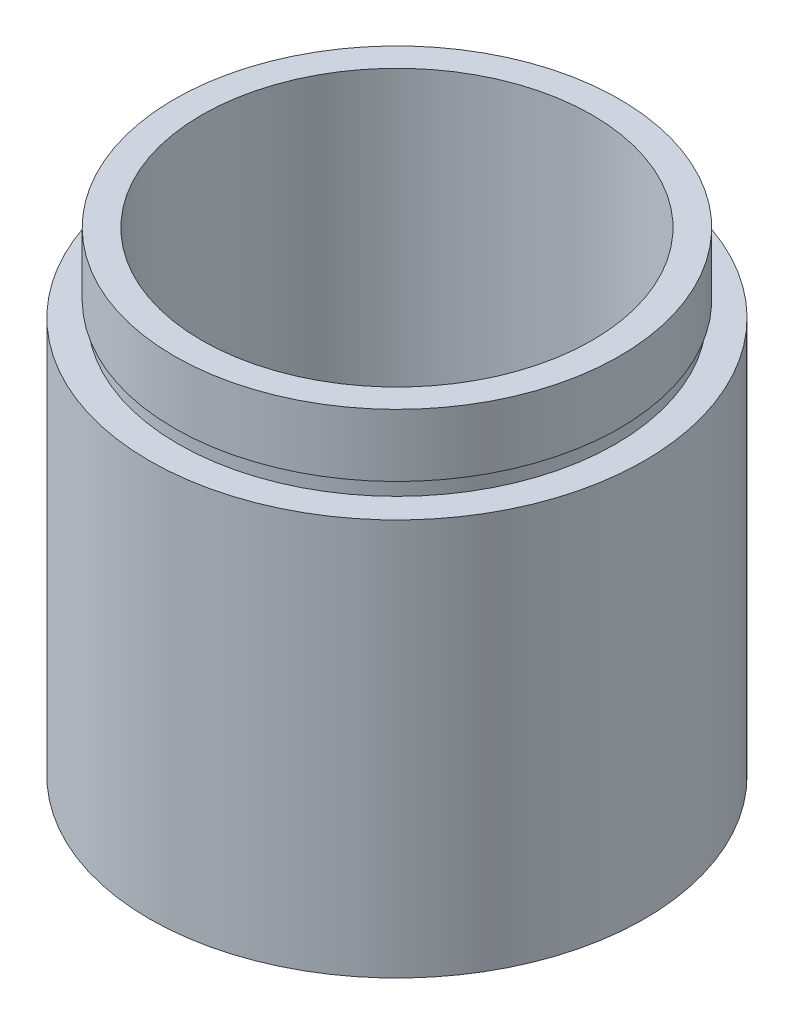
from build123d import *


with BuildPart() as part:
    # 草图1 → 旋转1 (revolve)
    with BuildSketch(Plane.XY, mode=Mode.PRIVATE) as revolve_1_sk:
        Polygon((14.25, 0), (14.25, 4.5), (14.35, 4.5), (14.35, 5.5), (12.5, 5.5), (12.5, 30.4), (14.25, 30.4), (14.25, 26.4), (14, 26.4), (14, 25.4), (15.85, 25.4), (15.85, 0), align=None)
    revolve(revolve_1_sk.sketch.rotate(Axis((0, 161.376166943, 0), (0, -1, 0)), 90), axis=Axis((0, 161.376166943, 0), (0, -1, 0)))  # turned: the seam where the file's is


solid = part.part
